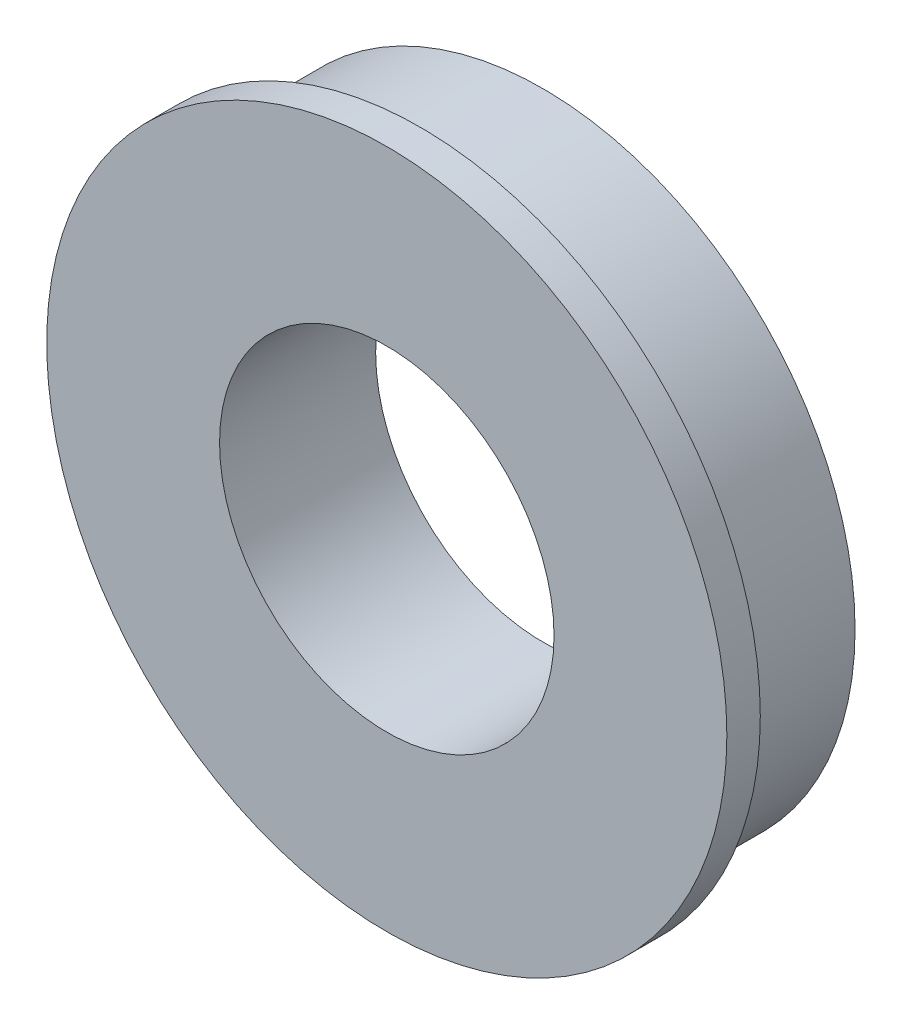
from build123d import *

# Parameters (mm, degrees)
SKETCH_1_R          = 14
EXTRUDE_1_DEPTH     = 5.5
SKETCH_2_R          = 15.25
EXTRUDE_2_DEPTH     = 1.5
CUT_EXTRUDE_1_REACH = 9
SKETCH_3_R          = 7.5


with BuildPart() as part:
    # 草图1 → 凸台-拉伸1 (new body)
    with BuildSketch(Plane.XY):
        Circle(SKETCH_1_R)
    extrude(amount=EXTRUDE_1_DEPTH)

    # 草图2 → 凸台-拉伸2 (add)
    with BuildSketch(Plane.XY.offset(5.5)):
        Circle(SKETCH_2_R)
    extrude(amount=EXTRUDE_2_DEPTH)

    # 草图3 → 切除-拉伸1 (cut, up to next)
    with BuildSketch(Plane(origin=(0, 0, 0), x_dir=(-1, 0, 0), z_dir=(0, 0, -1)), mode=Mode.PRIVATE) as cut_extrude_1_sk1:
        Circle(SKETCH_3_R)
    cut_extrude_1_tool1 = extrude(cut_extrude_1_sk1.sketch, amount=-CUT_EXTRUDE_1_REACH, mode=Mode.PRIVATE) & part.part
    add(cut_extrude_1_tool1.solids().sort_by_distance((0, 0, 0))[0], mode=Mode.SUBTRACT)


solid = part.part
